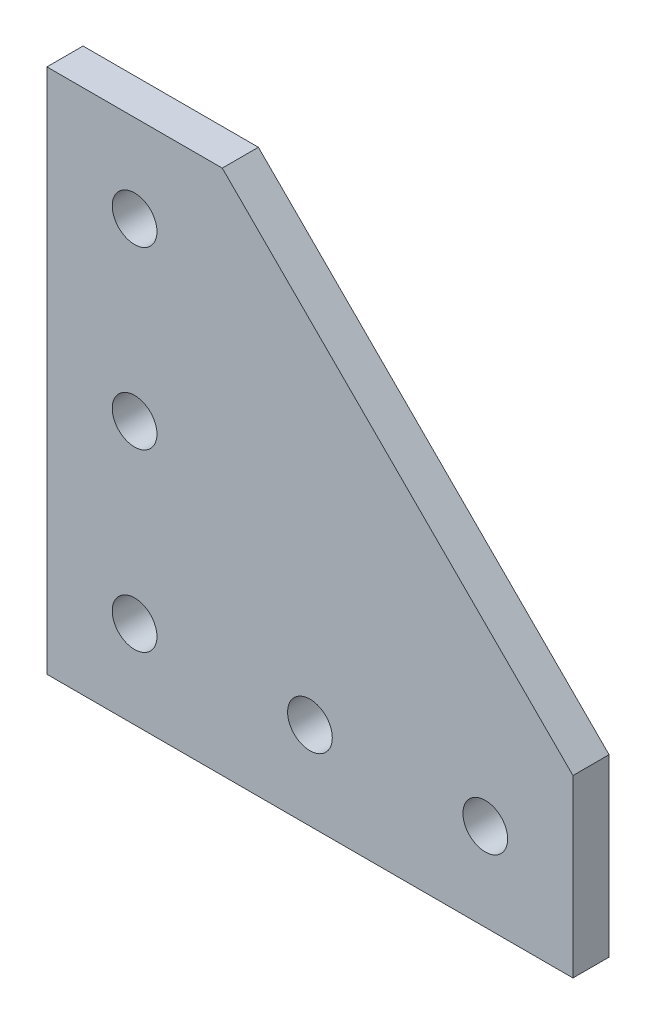
from build123d import *

# Parameters (mm, degrees)
BOSS_EXTRUDE1_DEPTH = 4.12
SKETCH2_R           = 2.55
CUT_EXTRUDE1_DEPTH  = 5.12


with BuildPart() as part:
    # Sketch1 → Boss-Extrude1 (new body)
    with BuildSketch(Plane.XY):
        Polygon((0, 0), (0, 60), (20, 60), (60, 20), (60, 0), align=None)
    extrude(amount=BOSS_EXTRUDE1_DEPTH)

    # Sketch2 → Cut-Extrude1 (cut, through all)
    with BuildSketch(Plane.XY.offset(4.12)):
        with Locations((10, 10)):
            Circle(SKETCH2_R)
        with Locations((30, 10)):
            Circle(SKETCH2_R)
        with Locations((50, 10)):
            Circle(SKETCH2_R)
        with Locations((10, 30)):
            Circle(SKETCH2_R)
        with Locations((10, 50)):
            Circle(SKETCH2_R)
    extrude(amount=-CUT_EXTRUDE1_DEPTH, mode=Mode.SUBTRACT)


solid = part.part
